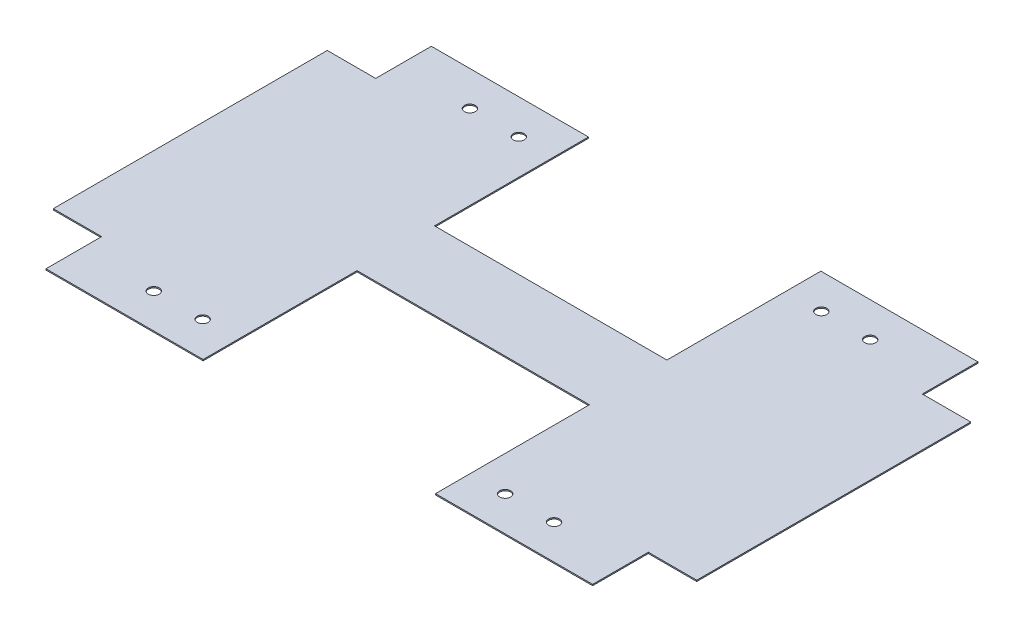
from build123d import *

# Parameters (mm, degrees)
SKETCH1_R           = 1.125
BOSS_EXTRUDE1_DEPTH = 0.25


with BuildPart() as part:
    # Sketch1 → Boss-Extrude1 (new body)
    with BuildSketch(Plane(origin=(0, 0, 0), x_dir=(1, 0, 0), z_dir=(0, 1, 0))):
        Polygon((-24, 39.8), (-24, 8), (24, 8), (24, 39.8), (56.46, 39.8), (56.46, 28.3), (66.46, 28.3), (66.46, -28.3), (56.46, -28.3), (56.46, -39.8), (24, -39.8), (24, -8), (-24, -8), (-24, -39.8), (-56.46, -39.8), (-56.46, -28.3), (-66.46, -28.3), (-66.46, 28.3), (-56.46, 28.3), (-56.46, 39.8), align=None)
        with Locations(Location((-41.34, 32.65, 0), (0, 0, 270))):  # turned: the seam where the file's is
            Circle(SKETCH1_R, mode=Mode.SUBTRACT)
        with Locations(Location((-31.24, 32.65, 0), (0, 0, 270))):  # turned: the seam where the file's is
            Circle(SKETCH1_R, mode=Mode.SUBTRACT)
        with Locations(Location((31.24, 32.65, 0), (0, 0, 270))):  # turned: the seam where the file's is
            Circle(SKETCH1_R, mode=Mode.SUBTRACT)
        with Locations(Location((41.34, 32.65, 0), (0, 0, 270))):  # turned: the seam where the file's is
            Circle(SKETCH1_R, mode=Mode.SUBTRACT)
        with Locations(Location((41.34, -32.65, 0), (0, 0, 270))):  # turned: the seam where the file's is
            Circle(SKETCH1_R, mode=Mode.SUBTRACT)
        with Locations(Location((31.24, -32.65, 0), (0, 0, 270))):  # turned: the seam where the file's is
            Circle(SKETCH1_R, mode=Mode.SUBTRACT)
        with Locations(Location((-31.24, -32.65, 0), (0, 0, 270))):  # turned: the seam where the file's is
            Circle(SKETCH1_R, mode=Mode.SUBTRACT)
        with Locations(Location((-41.34, -32.65, 0), (0, 0, 270))):  # turned: the seam where the file's is
            Circle(SKETCH1_R, mode=Mode.SUBTRACT)
    extrude(amount=BOSS_EXTRUDE1_DEPTH)


solid = part.part
